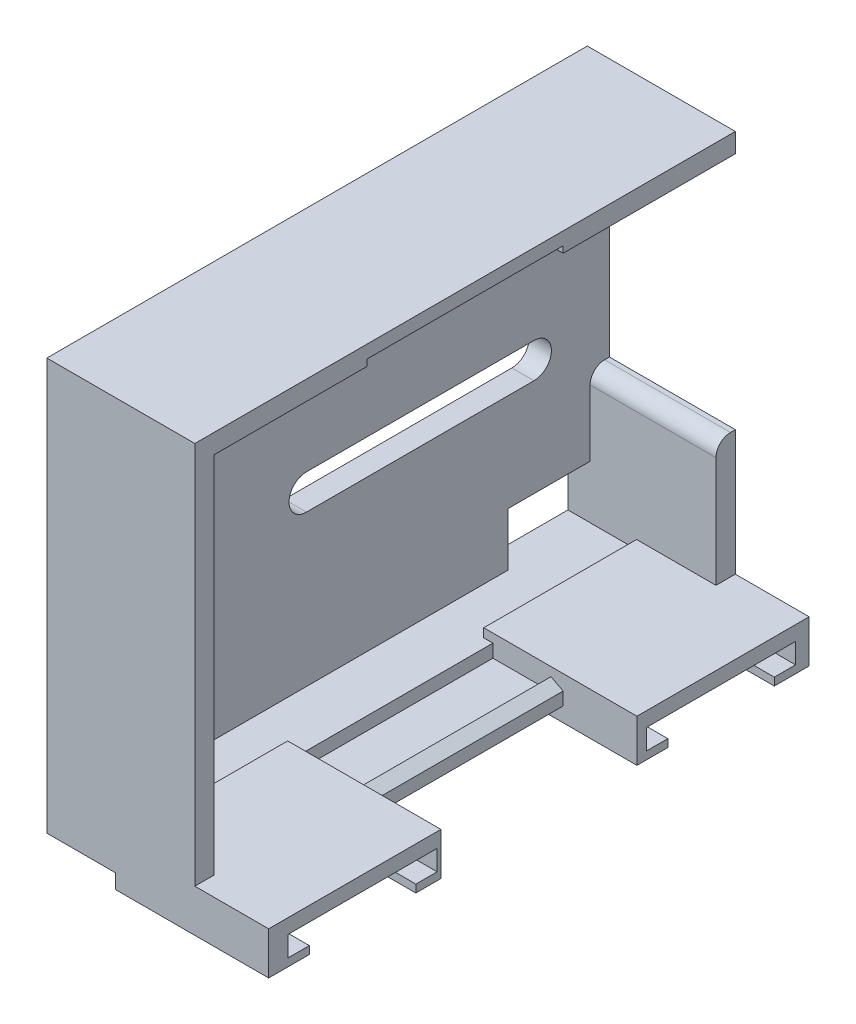
from build123d import *

# Parameters (mm, degrees)
MAIN_EXTRUDE_DEPTH          = 2.2875
WALLS_START                 = 2.2875
WALLS_DEPTH                 = 13
CORNER_SUPPORT_DEPTH        = 2
FILLET4_R                   = 2
SKETCH4_W                   = 8.5
SKETCH4_H                   = 5.5
WIRE_HOLE_DEPTH             = 40.380356778
SKETCH25_W                  = 6
SKETCH25_H                  = 1.35
FEMALE_SNAP_DEPTH           = 10.125
SKETCH30_W                  = 15.7875
SKETCH30_H                  = 0.9
SKETCH30_W_2                = 17.7875
SKETCH30_H_2                = 1.5
MAGNET_EXTRUDE_1_DEPTH      = 7.625
MAGNET_EXTRUDE_1_DEPTH_BACK = 8.2
SKETCH29_R                  = 7.7
MAGNET_HOLE_DEPTH           = 2.1
SKETCH31_R                  = 5.5
MAGNET_THRU_HOLE_DEPTH      = 58.632218908
SKETCH40_W                  = 15.2875
SKETCH40_H                  = 12.55
CUT_EXTRUDE2_DEPTH          = 6
SKETCH41_W                  = 13
SKETCH41_H                  = 2
BOSS_EXTRUDE1_DEPTH         = 9.4


with BuildPart() as part:
    # Sketch1 → Main Extrude (new body)
    with BuildSketch(Plane(origin=(0, 0, 0), x_dir=(0, 0, -1), z_dir=(1, 0, 0))):
        Polygon((-30.5, -9.35), (-27.325, -9.35), (-27.325, -21.25), (28.5, -21.25), (28.5, 21.25), (-27.325, 21.25), (-27.325, 3.2), (-30.5, 3.2), align=None)
        with BuildLine():
            Line((20.7, -3.65), (-2.8, -3.65))
            ThreePointArc((-2.8, -3.65), (-4.6, -1.85), (-2.8, -0.05))
            Line((-2.8, -0.05), (20.7, -0.05))
            ThreePointArc((20.7, -0.05), (22.5, -1.85), (20.7, -3.65))
        make_face(mode=Mode.SUBTRACT)
    extrude(amount=MAIN_EXTRUDE_DEPTH)

    # Sketch1_3 → Walls (add)
    with BuildSketch(Plane(origin=(0, 0, 0), x_dir=(0, 0, -1), z_dir=(1, 0, 0)).offset(WALLS_START)):
        Polygon((-25.325, 19.25), (28.5, 19.25), (28.5, 21.25), (-27.325, 21.25), (-27.325, 3.2), (-30.5, 3.2), (-30.5, 1.3), (-25.325, 1.3), align=None)
        with BuildLine():
            Line((28.5, -5.425), (28, -5.425))
            ThreePointArc((28, -5.425), (26.939339828, -5.864339828), (26.5, -6.925))
            Line((26.5, -6.925), (26.5, -19.25))
            Line((26.5, -19.25), (-25.325, -19.25))
            Line((-25.325, -19.25), (-25.325, -8.1))
            Line((-25.325, -8.1), (-28.5, -8.1))
            Line((-28.5, -8.1), (-28.5, -4.45))
            Line((-28.5, -4.45), (-30.5, -4.45))
            Line((-30.5, -4.45), (-30.5, -9.35))
            Line((-30.5, -9.35), (-27.325, -9.35))
            Line((-27.325, -9.35), (-27.325, -21.25))
            Line((-27.325, -21.25), (28.5, -21.25))
            Line((28.5, -21.25), (28.5, -5.425))
        make_face()
    extrude(amount=WALLS_DEPTH)

    # Sketch22 → Corner Support (add)
    with BuildSketch(Plane(origin=(0, 0, -28.5), x_dir=(-1, 0, 0), z_dir=(0, 0, -1))):
        Polygon((-4.2875, 19.25), (-2.2875, 18.25), (-2.2875, 19.25), align=None)
    extrude(amount=-CORNER_SUPPORT_DEPTH)

    # Fillet4
    fillet4_edges = [part.edges().sort_by_distance(p)[0] for p in [
        (2.2875, -1.575, 30.5),
    ]]
    fillet(fillet4_edges, radius=FILLET4_R)

    # Sketch4 → Wire Hole (cut, through all)
    with BuildSketch(Plane(origin=(2.2875, 0, 0), x_dir=(0, 0, -1), z_dir=(1, 0, 0))):
        with Locations((22.25, -16.5)):
            Rectangle(SKETCH4_W, SKETCH4_H)
    extrude(amount=-WIRE_HOLE_DEPTH, mode=Mode.SUBTRACT)

    # Sketch25 → Female Snap (cut, symmetric)
    with BuildSketch(Plane(origin=(0, 0, -0.5875), x_dir=(-1, 0, 0), z_dir=(0, 0, -1))):
        with Locations((-11.0375, -19.925)):
            Rectangle(SKETCH25_W, SKETCH25_H)
        Polygon((-15.2875, -19.25), (-15.2875, -19.91463679), (-14.0375, -19.25), align=None)
        with Locations((-11.0375, 19.925)):
            Rectangle(SKETCH25_W, SKETCH25_H)
        Polygon((-15.2875, 19.91463679), (-15.2875, 19.25), (-14.0375, 19.25), align=None)
    extrude(amount=FEMALE_SNAP_DEPTH, both=True, mode=Mode.SUBTRACT)

    # Sketch30 → Magnet Extrude 1 (add, two sides)
    with BuildSketch(Plane(origin=(15.2875, 0, 0), x_dir=(0, 0, -1), z_dir=(1, 0, 0))) as magnet_extrude_1_sk:
        Polygon((-27.325, -18.35), (-27.325, -21.25), (-9.5375, -21.25), (-9.5375, -19.91463679), (-9.5375, -19.25), (-25.325, -19.25), (-25.325, -18.35), align=None)
        with Locations((-17.43125, -18.8)):
            Rectangle(SKETCH30_W, SKETCH30_H)
        with Locations((19.60625, -22)):
            Rectangle(SKETCH30_W_2, SKETCH30_H_2)
        Polygon((10.7125, -19.91463679), (10.7125, -21.25), (28.5, -21.25), (28.5, -18.35), (26.5, -18.35), (26.5, -19.25), (10.7125, -19.25), align=None)
        with Locations((-18.43125, -22)):
            Rectangle(SKETCH30_W_2, SKETCH30_H_2)
        with Locations((18.60625, -18.8)):
            Rectangle(SKETCH30_W, SKETCH30_H)
    extrude(amount=MAGNET_EXTRUDE_1_DEPTH)
    extrude(magnet_extrude_1_sk.sketch, amount=-MAGNET_EXTRUDE_1_DEPTH_BACK)

    # Sketch29 → Magnet Hole (cut)
    with BuildSketch(Plane(origin=(0, -21.95, 0), x_dir=(1, 0, 0), z_dir=(0, 1, 0))):
        with Locations((15.2875, -17.625)):
            Circle(SKETCH29_R)
        with BuildLine():
            ThreePointArc((22.9125, -18.697089082), (20.338980677, -23.436414885), (15.2875, -25.325))
            Line((15.2875, -25.325), (22.9125, -25.325))
            Line((22.9125, -25.325), (22.9125, -18.697089082))
        make_face()
        with BuildLine():
            Line((22.9125, -9.925), (15.2875, -9.925))
            ThreePointArc((15.2875, -9.925), (20.338980677, -11.813585115), (22.9125, -16.552910918))
            Line((22.9125, -16.552910918), (22.9125, -9.925))
        make_face()
        with Locations((15.2875, 19.4)):
            Circle(SKETCH29_R)
        with BuildLine():
            ThreePointArc((22.9125, 18.327910918), (20.338980677, 13.588585115), (15.2875, 11.7))
            Line((15.2875, 11.7), (22.9125, 11.7))
            Line((22.9125, 11.7), (22.9125, 18.327910918))
        make_face()
        with BuildLine():
            Line((22.9125, 27.1), (15.2875, 27.1))
            ThreePointArc((15.2875, 27.1), (20.338980677, 25.211414885), (22.9125, 20.472089082))
            Line((22.9125, 20.472089082), (22.9125, 27.1))
        make_face()
        with BuildLine():
            ThreePointArc((22.9875, -17.625), (22.968727116, -17.087645368), (22.9125, -16.552910918))
            Line((22.9125, -16.552910918), (22.9125, -18.697089082))
            ThreePointArc((22.9125, -18.697089082), (22.968727116, -18.162354632), (22.9875, -17.625))
        make_face()
        with BuildLine():
            Line((22.9125, 20.472089082), (22.9125, 18.327910918))
            ThreePointArc((22.9125, 18.327910918), (22.968727116, 18.862645368), (22.9875, 19.4))
            ThreePointArc((22.9875, 19.4), (22.968727116, 19.937354632), (22.9125, 20.472089082))
        make_face()
    extrude(amount=MAGNET_HOLE_DEPTH, mode=Mode.SUBTRACT)

    # Sketch31 → Magnet Thru Hole (cut, through all)
    with BuildSketch(Plane.XZ.offset(21.95)):
        with Locations((15.2875, 17.625)):
            Circle(SKETCH31_R)
        with BuildLine():
            Line((22.9125, 23.125), (15.2875, 23.125))
            ThreePointArc((15.2875, 23.125), (19.176587297, 21.514087297), (20.7875, 17.625))
            ThreePointArc((20.7875, 17.625), (19.176587297, 13.735912703), (15.2875, 12.125))
            Line((15.2875, 12.125), (22.9125, 12.125))
            Line((22.9125, 12.125), (22.9125, 23.125))
        make_face()
        with Locations((15.2875, -19.4)):
            Circle(SKETCH31_R)
        with BuildLine():
            Line((22.9125, -13.9), (15.2875, -13.9))
            ThreePointArc((15.2875, -13.9), (19.176587297, -15.510912703), (20.7875, -19.4))
            ThreePointArc((20.7875, -19.4), (19.176587297, -23.289087297), (15.2875, -24.9))
            Line((15.2875, -24.9), (22.9125, -24.9))
            Line((22.9125, -24.9), (22.9125, -13.9))
        make_face()
    extrude(amount=MAGNET_THRU_HOLE_DEPTH, mode=Mode.SUBTRACT)

    # Sketch40 → Cut-Extrude2 (cut)
    with BuildSketch(Plane.XY.offset(27.325)):
        with Locations((7.64375, -3.075)):
            Rectangle(SKETCH40_W, SKETCH40_H)
    extrude(amount=CUT_EXTRUDE2_DEPTH, mode=Mode.SUBTRACT)

    # Sketch41 → Boss-Extrude1 (add)
    with BuildSketch(Plane.XZ.offset(-1.3)):
        with Locations((8.7875, 26.325)):
            Rectangle(SKETCH41_W, SKETCH41_H)
    extrude(amount=BOSS_EXTRUDE1_DEPTH)


solid = part.part
